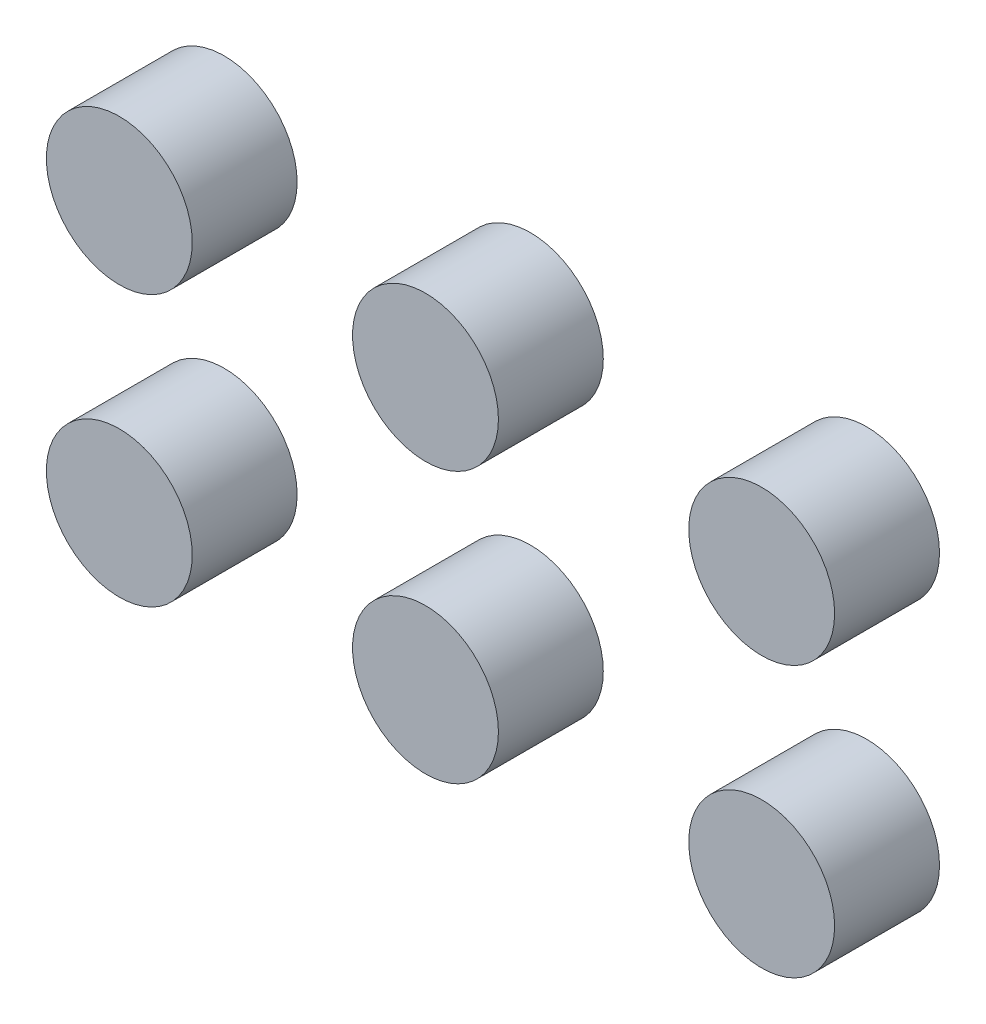
from build123d import *

# Parameters (mm, degrees)
SKETCH1_R             = 27.817474812
BOSS_EXTRUDE1_DEPTH   = 40
BOSS_EXTRUDE1_2_DEPTH = 40
BOSS_EXTRUDE1_3_DEPTH = 40
BOSS_EXTRUDE1_4_DEPTH = 40
BOSS_EXTRUDE1_5_DEPTH = 40
BOSS_EXTRUDE1_6_DEPTH = 40


with BuildPart() as part:
    # Sketch1 → Boss-Extrude1 (new body)
    with BuildSketch(Plane.XY):
        with Locations((-136.770389137, 40.298418228)):
            Circle(SKETCH1_R)
    extrude(amount=BOSS_EXTRUDE1_DEPTH)


with BuildPart() as body_2:
    # Sketch1 → Boss-Extrude1 2 (new body)
    with BuildSketch(Plane.XY):
        with Locations((-19.99656359, 40.298418228)):
            Circle(SKETCH1_R)
    extrude(amount=BOSS_EXTRUDE1_2_DEPTH)


with BuildPart() as body_3:
    # Sketch1 → Boss-Extrude1 3 (new body)
    with BuildSketch(Plane.XY):
        with Locations((108.225676226, 40.298418228)):
            Circle(SKETCH1_R)
    extrude(amount=BOSS_EXTRUDE1_3_DEPTH)


with BuildPart() as body_4:
    # Sketch1 → Boss-Extrude1 4 (new body)
    with BuildSketch(Plane.XY):
        with Locations((-136.770389137, -62.889955719)):
            Circle(SKETCH1_R)
    extrude(amount=BOSS_EXTRUDE1_4_DEPTH)


with BuildPart() as body_5:
    # Sketch1 → Boss-Extrude1 5 (new body)
    with BuildSketch(Plane.XY):
        with Locations((-19.99656359, -62.889955719)):
            Circle(SKETCH1_R)
    extrude(amount=BOSS_EXTRUDE1_5_DEPTH)


with BuildPart() as body_6:
    # Sketch1 → Boss-Extrude1 6 (new body)
    with BuildSketch(Plane.XY):
        with Locations((108.225676226, -62.889955719)):
            Circle(SKETCH1_R)
    extrude(amount=BOSS_EXTRUDE1_6_DEPTH)


solid = Compound([part.part, body_2.part, body_3.part, body_4.part, body_5.part, body_6.part])
